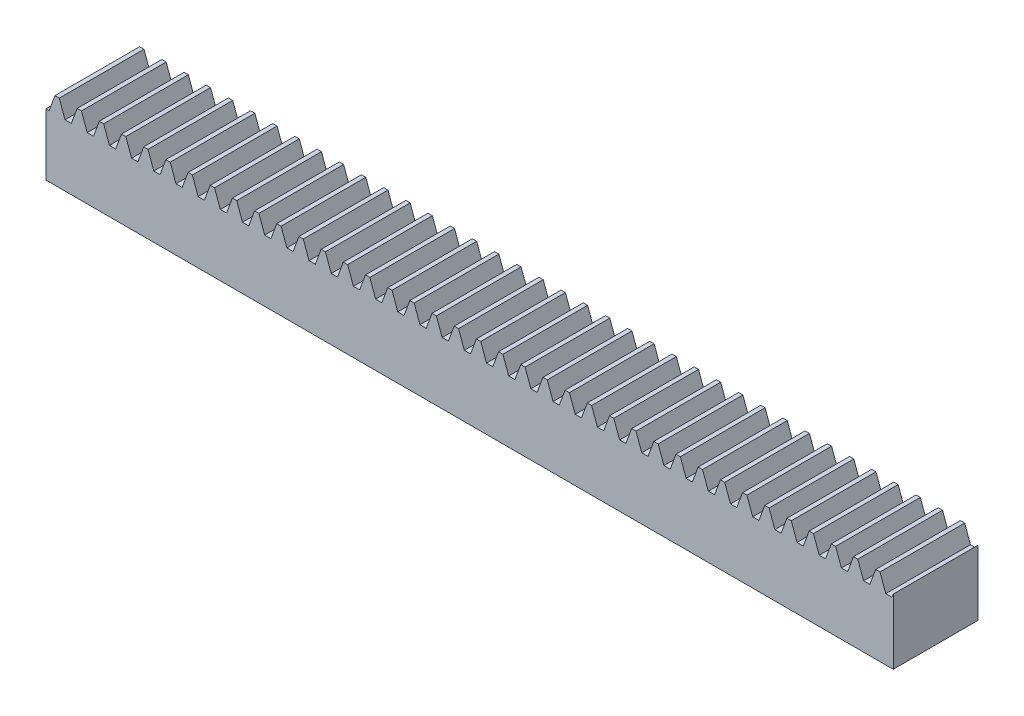
from build123d import *

# Parameters (mm, degrees)
BLANKSKE_W        = 120
BLANKSKE_H        = 11
BLANK_DEPTH       = 12
TOOTHCUTSIM_DEPTH = 122.099132945
TEETHCUTS_COUNT   = 39
TEETHCUTS_PITCH   = 3.14159265


with BuildPart() as part:
    # BlankSke → Blank (new body)
    with BuildSketch(Plane.XY):
        with Locations((60, 5.5)):
            Rectangle(BLANKSKE_W, BLANKSKE_H)
    extrude(amount=-BLANK_DEPTH)

    # TooCutSkeSim → ToothCutSim (cut, through all)
    with BuildSketch(Plane.XY):
        Polygon((0.44443537, 8.75), (-0.44443537, 8.75), (-1.272613241, 11.0254), (1.272613241, 11.0254), align=None)
    toothcutsim = extrude(amount=-TOOTHCUTSIM_DEPTH, mode=Mode.SUBTRACT)

    # TeethCuts: ToothCutSim ×39
    with Locations(*[(i * TEETHCUTS_PITCH, 0, 0) for i in range(1, TEETHCUTS_COUNT)]):
        add(toothcutsim, mode=Mode.SUBTRACT)


solid = part.part
